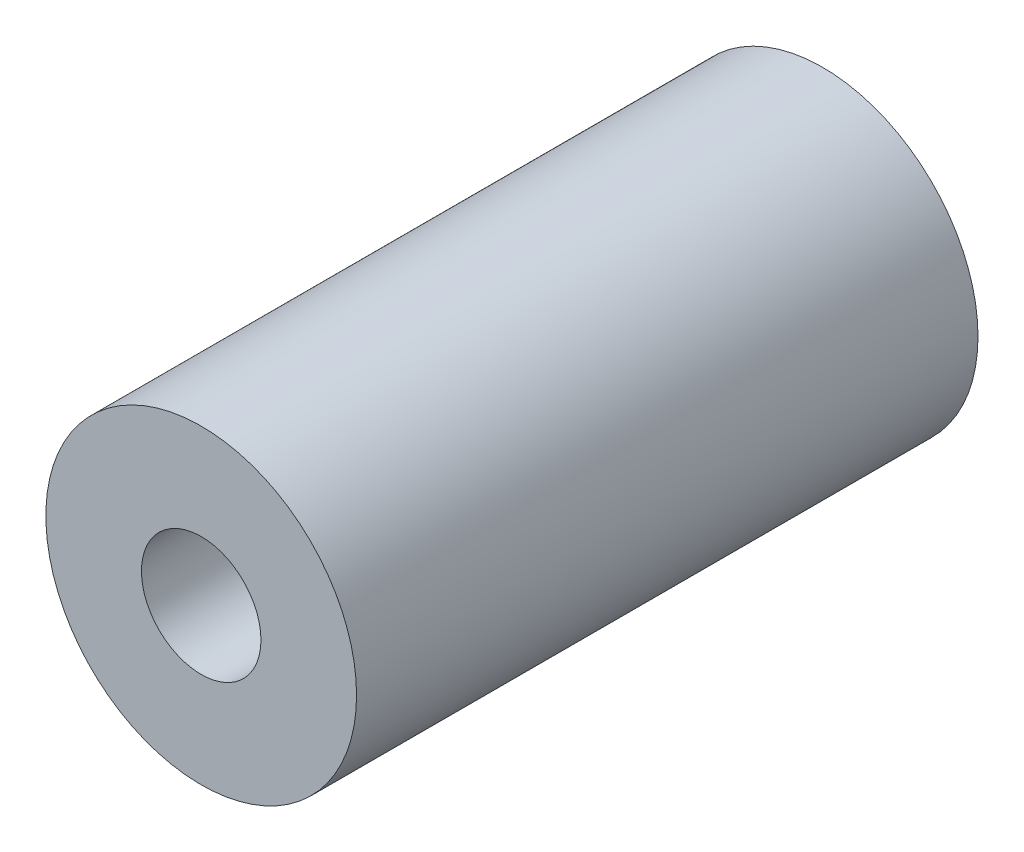
from build123d import *

# Parameters (mm, degrees)
SKETCH_1_R      = 3.25
SKETCH_1_R_2    = 1.25
EXTRUDE_1_DEPTH = 13


with BuildPart() as part:
    # 草图1 → 凸台-拉伸1 (new body)
    with BuildSketch(Plane.XY):
        Circle(SKETCH_1_R)
        Circle(SKETCH_1_R_2, mode=Mode.SUBTRACT)
    extrude(amount=EXTRUDE_1_DEPTH)


solid = part.part
